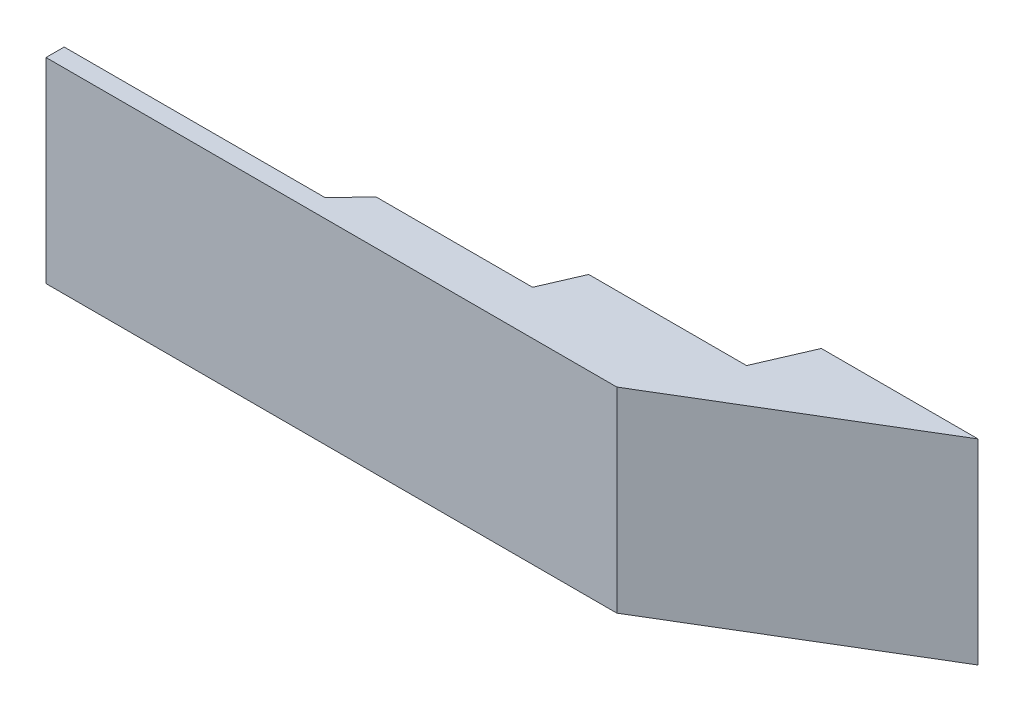
from build123d import *

# Parameters (mm, degrees)
BOSS_EXTRUDE1_DEPTH = 1500


with BuildPart() as part:
    # Sketch1 → Boss-Extrude1 (new body)
    with BuildSketch(Plane(origin=(0, 0, 0), x_dir=(1, 0, 0), z_dir=(0, 1, 0))):
        Polygon((-2629.104477612, 0), (-629.104477612, 0), (-441.044776119, 200), (29.104477612, 200), (758.955223881, 200), (888.805970149, 500), (2097.76119403, 500), (2270.895522388, 900), (3470.895522388, 900), (1743.375754441, -139.280385584), (-2629.104477612, -139.280385584), align=None)
    extrude(amount=BOSS_EXTRUDE1_DEPTH)


solid = part.part
